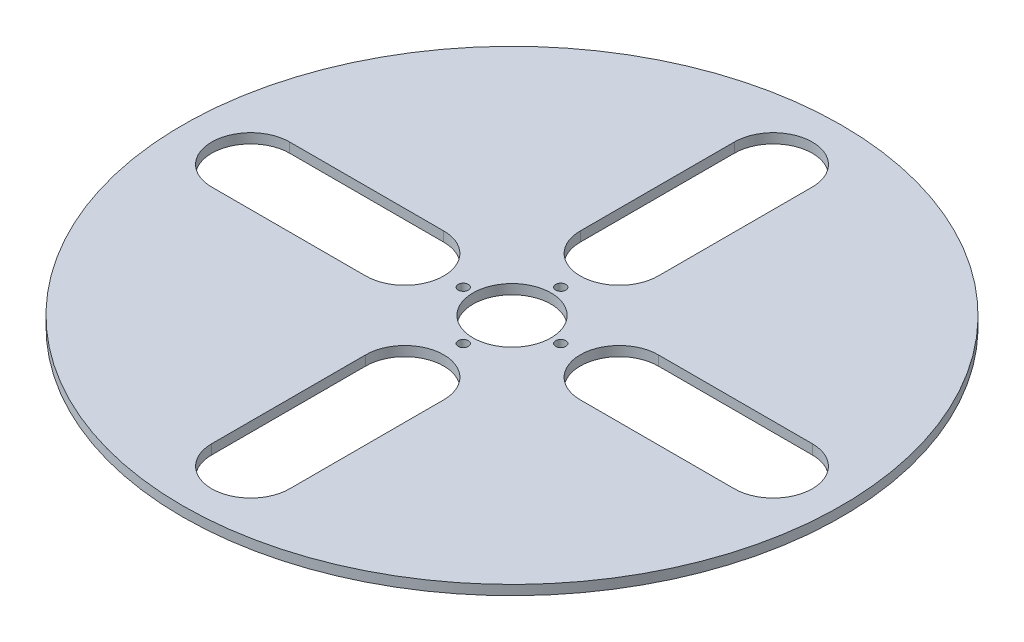
from build123d import *

# Parameters (mm, degrees)
SKETCH1_R           = 214.63
SKETCH1_R_2         = 25.4
BOSS_EXTRUDE1_DEPTH = 6.35
SKETCH3_R           = 3.2893
CUT_EXTRUDE2_DEPTH  = 7.35
CUT_EXTRUDE3_DEPTH  = 7.35


with BuildPart() as part:
    # Sketch1 → Boss-Extrude1 (new body)
    with BuildSketch(Plane(origin=(0, 0, 0), x_dir=(1, 0, 0), z_dir=(0, 1, 0))):
        Circle(SKETCH1_R)
        Circle(SKETCH1_R_2, mode=Mode.SUBTRACT)
    extrude(amount=BOSS_EXTRUDE1_DEPTH)

    # Sketch3 → Cut-Extrude2 (cut, through all)
    with BuildSketch(Plane(origin=(0, 6.35, 0), x_dir=(1, 0, 0), z_dir=(0, 1, 0))):
        with Locations((0, 31.75)):
            Circle(SKETCH3_R)
        with Locations((31.75, 0)):
            Circle(SKETCH3_R)
        with Locations((0, -31.75)):
            Circle(SKETCH3_R)
        with Locations((-31.75, 0)):
            Circle(SKETCH3_R)
    extrude(amount=-CUT_EXTRUDE2_DEPTH, mode=Mode.SUBTRACT)

    # Sketch4 → Cut-Extrude3 (cut, through all)
    with BuildSketch(Plane(origin=(0, 6.35, 0), x_dir=(1, 0, 0), z_dir=(0, 1, 0))):
        with BuildLine():
            Line((25.4, 170.18), (25.4, 69.85))
            ThreePointArc((25.4, 69.85), (0, 44.45), (-25.4, 69.85))
            Line((-25.4, 69.85), (-25.4, 170.18))
            ThreePointArc((-25.4, 170.18), (0, 195.58), (25.4, 170.18))
        make_face()
        with BuildLine():
            Line((170.18, -25.4), (69.85, -25.4))
            ThreePointArc((69.85, -25.4), (44.45, 0), (69.85, 25.4))
            Line((69.85, 25.4), (170.18, 25.4))
            ThreePointArc((170.18, 25.4), (195.58, 0), (170.18, -25.4))
        make_face()
        with BuildLine():
            Line((-25.4, -170.18), (-25.4, -69.85))
            ThreePointArc((-25.4, -69.85), (0, -44.45), (25.4, -69.85))
            Line((25.4, -69.85), (25.4, -170.18))
            ThreePointArc((25.4, -170.18), (0, -195.58), (-25.4, -170.18))
        make_face()
        with BuildLine():
            Line((-170.18, 25.4), (-69.85, 25.4))
            ThreePointArc((-69.85, 25.4), (-44.45, 0), (-69.85, -25.4))
            Line((-69.85, -25.4), (-170.18, -25.4))
            ThreePointArc((-170.18, -25.4), (-195.58, 0), (-170.18, 25.4))
        make_face()
    extrude(amount=-CUT_EXTRUDE3_DEPTH, mode=Mode.SUBTRACT)


solid = part.part
